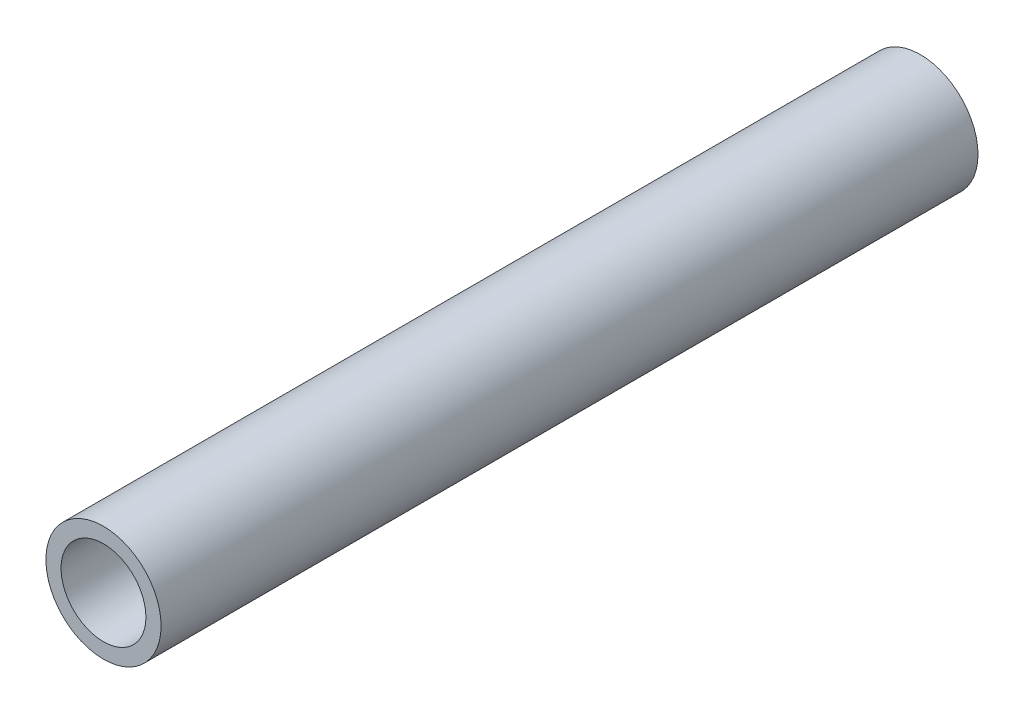
from build123d import *

# Parameters (mm, degrees)
SKETCH1_R           = 4.826
SKETCH1_R_2         = 3.556
BOSS_EXTRUDE1_DEPTH = 68.453


with BuildPart() as part:
    # Sketch1 → Boss-Extrude1 (new body)
    with BuildSketch(Plane.XY):
        Circle(SKETCH1_R)
        Circle(SKETCH1_R_2, mode=Mode.SUBTRACT)
    extrude(amount=BOSS_EXTRUDE1_DEPTH)


solid = part.part
